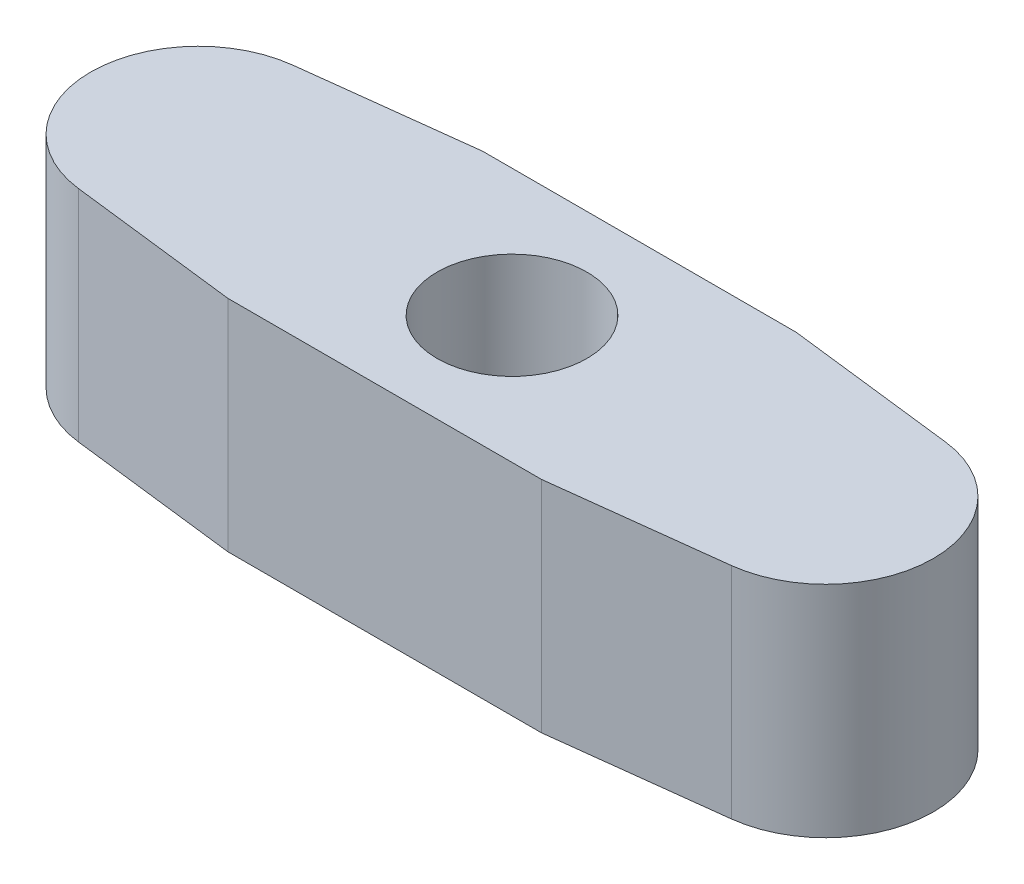
from build123d import *

# Parameters (mm, degrees)
SKETCH4_R           = 1.911425658
BOSS_EXTRUDE1_DEPTH = 5.6


with BuildPart() as part:
    # Sketch4 → Boss-Extrude1 (new body)
    with BuildSketch(Plane(origin=(0, 0, 0), x_dir=(1, 0, 0), z_dir=(0, 1, 0))):
        with BuildLine():
            Line((-4, -3.25), (-8.327817762, -2.730391092))
            ThreePointArc((-8.327817762, -2.730391092), (-10.75, 0), (-8.327817762, 2.730391092))
            Line((-8.327817762, 2.730391092), (-4, 3.25))
            Line((-4, 3.25), (4, 3.25))
            Line((4, 3.25), (8.327817762, 2.730391092))
            ThreePointArc((8.327817762, 2.730391092), (10.75, 0), (8.327817762, -2.730391092))
            Line((8.327817762, -2.730391092), (4, -3.25))
            Line((4, -3.25), (-4, -3.25))
        make_face()
        Circle(SKETCH4_R, mode=Mode.SUBTRACT)
    extrude(amount=BOSS_EXTRUDE1_DEPTH)


solid = part.part
